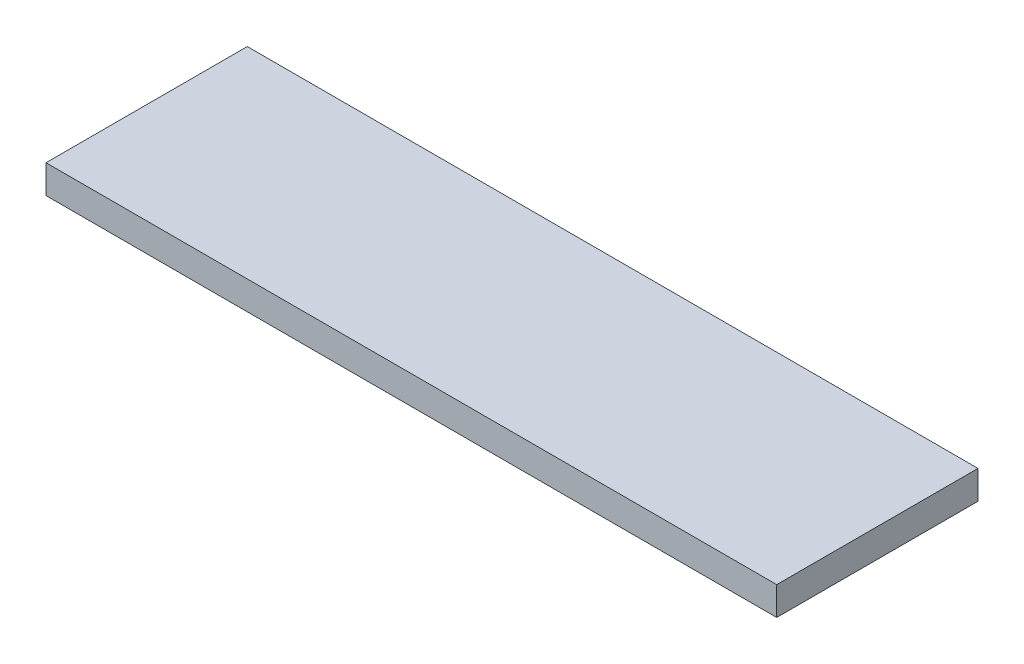
from build123d import *

# Parameters (mm, degrees)
BOSS_EXTRUDE1_DEPTH = 3


with BuildPart() as part:
    # Sketch1 → Boss-Extrude1 (new body)
    with BuildSketch(Plane(origin=(0, 0, 0), x_dir=(1, 0, 0), z_dir=(0, 1, 0))):
        Polygon((-38.472622478, 6.747838617), (-38.472622478, 14.747838617), (-30.472622478, 14.747838617), (38.527377522, 14.747838617), (38.527377522, -6.462161383), (-38.472622478, -6.462161383), align=None)
    extrude(amount=BOSS_EXTRUDE1_DEPTH)


solid = part.part
